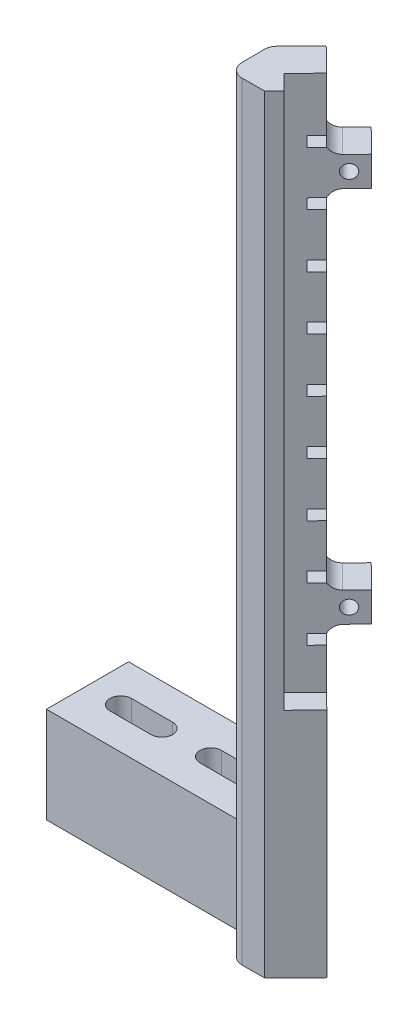
from build123d import *

# Parameters (mm, degrees)
SKETCH1_W                                 = 48.26
SKETCH1_H                                 = 17.78
BOSS_EXTRUDE1_DEPTH                       = 15.24
CUT_EXTRUDE2_DEPTH                        = 18.78
BOSS_EXTRUDE7_DEPTH                       = 124.7199944
BOSS_EXTRUDE10_DEPTH                      = 17.78
BOSS_EXTRUDE11_DEPTH                      = 25.2199902
TAPPED_HOLE_FOR_M2_5X0_45_HELICOIL1_D     = 2.55
TAPPED_HOLE_FOR_M2_5X0_45_HELICOIL1_DEPTH = 6.179587557
CUT_EXTRUDE3_DEPTH                        = 43.829137561
FILLET1_R                                 = 2.54
FILLET2_R                                 = 2.54


with BuildPart() as part:
    # Sketch1 → Boss-Extrude1 (new body)
    with BuildSketch(Plane.XY):
        with Locations((24.13, 8.89)):
            Rectangle(SKETCH1_W, SKETCH1_H)
    extrude(amount=-BOSS_EXTRUDE1_DEPTH)

    # Sketch4 → Cut-Extrude2 (cut, through all)
    with BuildSketch(Plane(origin=(0, 17.78, 0), x_dir=(1, 0, 0), z_dir=(0, 1, 0))):
        with BuildLine():
            Line((30.48, 5.62), (22.86, 5.62))
            ThreePointArc((22.86, 5.62), (20.86, 7.62), (22.86, 9.62))
            Line((22.86, 9.62), (30.48, 9.62))
            ThreePointArc((30.48, 9.62), (32.48, 7.62), (30.48, 5.62))
        make_face()
        with BuildLine():
            Line((13.78, 5.62), (6.16, 5.62))
            ThreePointArc((6.16, 5.62), (4.16, 7.62), (6.16, 9.62))
            Line((6.16, 9.62), (13.78, 9.62))
            ThreePointArc((13.78, 9.62), (15.78, 7.62), (13.78, 5.62))
        make_face()
    extrude(amount=-CUT_EXTRUDE2_DEPTH, mode=Mode.SUBTRACT)

    # Sketch3 → Boss-Extrude7 (add)
    with BuildSketch(Plane(origin=(0, 17.78, 0), x_dir=(1, 0, 0), z_dir=(0, 1, 0))):
        Polygon((38.861027897, 2.455591764), (38.931451129, -0.066795908), (38.96812041, -5.202868615), (45.652609046, -5.155144331), (47.435791814, -3.346316197), (44.587248028, -0.538158749), (52.660713317, 7.651417444), (48.26, 11.989737935), align=None)
    extrude(amount=BOSS_EXTRUDE7_DEPTH)

    # Sketch3_15 → Boss-Extrude10 (add, through all)
    with BuildSketch(Plane(origin=(0, 17.78, 0), x_dir=(1, 0, 0), z_dir=(0, 1, 0))):
        Polygon((38.929586235, 0), (38.931451129, -0.066795908), (38.96812041, -5.202868615), (45.652609046, -5.155144331), (51.367206426, 0.641639204), (48.518662639, 3.449796653), (52.660713317, 7.651417444), (48.26, 11.989737935), (48.26, 0), align=None)
    extrude(amount=-BOSS_EXTRUDE10_DEPTH)

    # Sketch3_16 → Boss-Extrude11 (add)
    with BuildSketch(Plane(origin=(0, 17.78, 0), x_dir=(1, 0, 0), z_dir=(0, 1, 0))):
        Polygon((48.26, 0), (45.117776821, 0), (44.587248028, -0.538158749), (47.435791814, -3.346316197), (51.367206426, 0.641639204), (48.518662639, 3.449796653), (48.26, 3.187413981), align=None)
        Polygon((48.26, 3.187413981), (45.117776821, 0), (48.26, 0), align=None)
    extrude(amount=BOSS_EXTRUDE11_DEPTH)

    # Tapped Hole for M2.5x0.45 Helicoil1
    with Locations(Plane(origin=(72.176615664, -14.555024135, -27.447993454), x_dir=(0.70204046, 0, -0.71213706), z_dir=(0.71213706, 0, 0.70204046))):
        with Locations((-30.748832903, 71.255012335), (-30.748832903, 141.254872335)):
            Hole(TAPPED_HOLE_FOR_M2_5X0_45_HELICOIL1_D / 2, depth=TAPPED_HOLE_FOR_M2_5X0_45_HELICOIL1_DEPTH)

    # Sketch10 → Cut-Extrude3 (cut, through all)
    with BuildSketch(Plane(origin=(22.88099291, 0, 22.556588727), x_dir=(0.70204046, 0, -0.71213706), z_dir=(0.71213706, 0, 0.70204046))):
        with BuildLine():
            Line((44.733441395, 142.4999944), (36.518809323, 142.4999944))
            Line((36.518809323, 142.4999944), (36.518802204, 132.4999944))
            Line((36.518802204, 132.4999944), (33.918802204, 132.499996251))
            Line((33.918802204, 132.499996251), (33.918800852, 130.599996251))
            Line((33.918800852, 130.599996251), (36.518800852, 130.5999944))
            ThreePointArc((36.518800852, 130.5999944), (37.424004911, 129.756252659), (38.622962574, 129.449992902))
            Line((38.622962574, 129.449992902), (42.418809323, 129.4499902))
            Line((42.418809323, 129.4499902), (42.418809323, 123.9499902))
            Line((42.418809323, 123.9499902), (38.787619584, 123.9499902))
            ThreePointArc((38.787619584, 123.9499902), (37.441328382, 123.556527643), (36.518809323, 122.4999902))
            Line((36.518809323, 122.4999902), (33.918809323, 122.4999902))
            Line((33.918809323, 122.4999902), (33.918809323, 120.5999902))
            Line((33.918809323, 120.5999902), (36.518809323, 120.5999902))
            Line((36.518809323, 120.5999902), (36.518809323, 112.4999902))
            Line((36.518809323, 112.4999902), (33.918809323, 112.4999902))
            Line((33.918809323, 112.4999902), (33.918809323, 110.5999902))
            Line((33.918809323, 110.5999902), (36.518809323, 110.5999902))
            Line((36.518809323, 110.5999902), (36.518809323, 102.4999902))
            Line((36.518809323, 102.4999902), (33.918809323, 102.4999902))
            Line((33.918809323, 102.4999902), (33.918809323, 100.5999902))
            Line((33.918809323, 100.5999902), (36.518809323, 100.5999902))
            Line((36.518809323, 100.5999902), (36.518809323, 92.4999902))
            Line((36.518809323, 92.4999902), (33.918809323, 92.4999902))
            Line((33.918809323, 92.4999902), (33.918809323, 90.5999902))
            Line((33.918809323, 90.5999902), (36.518809323, 90.5999902))
            Line((36.518809323, 90.5999902), (36.518809323, 82.4999902))
            Line((36.518809323, 82.4999902), (33.918809323, 82.4999902))
            Line((33.918809323, 82.4999902), (33.918809323, 80.5999902))
            Line((33.918809323, 80.5999902), (36.518809323, 80.5999902))
            Line((36.518809323, 80.5999902), (36.518809323, 72.4999902))
            Line((36.518809323, 72.4999902), (33.918809323, 72.4999902))
            Line((33.918809323, 72.4999902), (33.918809323, 70.5999902))
            Line((33.918809323, 70.5999902), (36.518809323, 70.5999902))
            Line((36.518809323, 70.5999902), (36.518809323, 62.4999902))
            Line((36.518809323, 62.4999902), (33.918809323, 62.4999902))
            Line((33.918809323, 62.4999902), (33.918809323, 60.5999902))
            Line((33.918809323, 60.5999902), (36.518809323, 60.5999902))
            ThreePointArc((36.518809323, 60.5999902), (37.424013983, 59.756249103), (38.622971864, 59.4499902))
            Line((38.622971864, 59.4499902), (42.418809323, 59.4499902))
            Line((42.418809323, 59.4499902), (42.418809323, 53.9499902))
            Line((42.418809323, 53.9499902), (38.787619584, 53.9499902))
            ThreePointArc((38.787619584, 53.9499902), (37.441328382, 53.556527643), (36.518809323, 52.4999902))
            Line((36.518809323, 52.4999902), (33.918809323, 52.4999902))
            Line((33.918809323, 52.4999902), (33.918809323, 50.5999902))
            Line((33.918809323, 50.5999902), (36.518809323, 50.5999902))
            Line((36.518809323, 50.5999902), (36.518809323, 42.9999902))
            Line((36.518809323, 42.9999902), (36.518792281, 0))
            Line((36.518792281, 0), (44.733441395, 0))
            Line((44.733441395, 0), (44.733441395, 142.4999944))
        make_face()
    extrude(amount=-CUT_EXTRUDE3_DEPTH, mode=Mode.SUBTRACT)

    # Fillet1
    fillet1_edges = [part.edges().sort_by_distance(p)[0] for p in [
        (38.96812041, 71.2499972, 5.202868615),
    ]]
    fillet(fillet1_edges, radius=FILLET1_R)

    # Fillet2
    fillet2_edges = [part.edges().sort_by_distance(p)[0] for p in [
        (38.861027897, 80.1399972, -2.455591764),
    ]]
    fillet(fillet2_edges, radius=FILLET2_R)


solid = part.part
